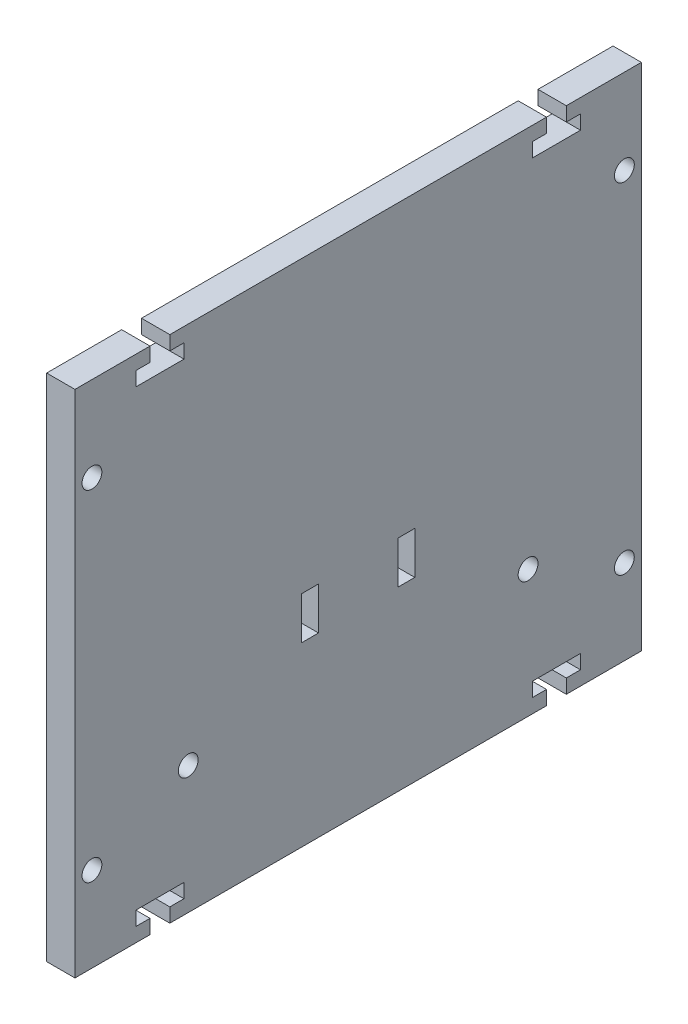
from build123d import *

# Parameters (mm, degrees)
SKETCH_1_R      = 1.75
SKETCH_1_W      = 3
SKETCH_1_H      = 7.5
EXTRUDE_1_DEPTH = 5


with BuildPart() as part:
    # Эскиз1 → Бобышка-Вытянуть1 (new body)
    with BuildSketch(Plane(origin=(0, 0, 0), x_dir=(0, 0, -1), z_dir=(1, 0, 0))):
        Polygon((-36.75, 45), (-36.75, 42.5), (-39.25, 42.5), (-39.25, 40), (-30.75, 40), (-30.75, 42.5), (-33.25, 42.5), (-33.25, 45), (33.25, 45), (33.25, 42.5), (30.75, 42.5), (30.75, 40), (39.25, 40), (39.25, 42.5), (36.75, 42.5), (36.75, 45), (50, 45), (50, -45), (36.75, -45), (36.75, -42.5), (39.25, -42.5), (39.25, -40), (30.75, -40), (30.75, -42.5), (33.25, -42.5), (33.25, -45), (-33.25, -45), (-33.25, -42.5), (-30.75, -42.5), (-30.75, -40), (-39.25, -40), (-39.25, -42.5), (-36.75, -42.5), (-36.75, -45), (-50, -45), (-50, 45), align=None)
        with Locations((-47, 30)):
            Circle(SKETCH_1_R, mode=Mode.SUBTRACT)
        with Locations((47, 30)):
            Circle(SKETCH_1_R, mode=Mode.SUBTRACT)
        with Locations((47, -30)):
            Circle(SKETCH_1_R, mode=Mode.SUBTRACT)
        with Locations((-47, -30)):
            Circle(SKETCH_1_R, mode=Mode.SUBTRACT)
        with Locations((-30, -22.5)):
            Circle(SKETCH_1_R, mode=Mode.SUBTRACT)
        with Locations((30, -22.5)):
            Circle(SKETCH_1_R, mode=Mode.SUBTRACT)
        with Locations((8.5, -10)):
            Rectangle(SKETCH_1_W, SKETCH_1_H, mode=Mode.SUBTRACT)
        with Locations((-8.5, -10)):
            Rectangle(SKETCH_1_W, SKETCH_1_H, mode=Mode.SUBTRACT)
    extrude(amount=EXTRUDE_1_DEPTH)


solid = part.part
